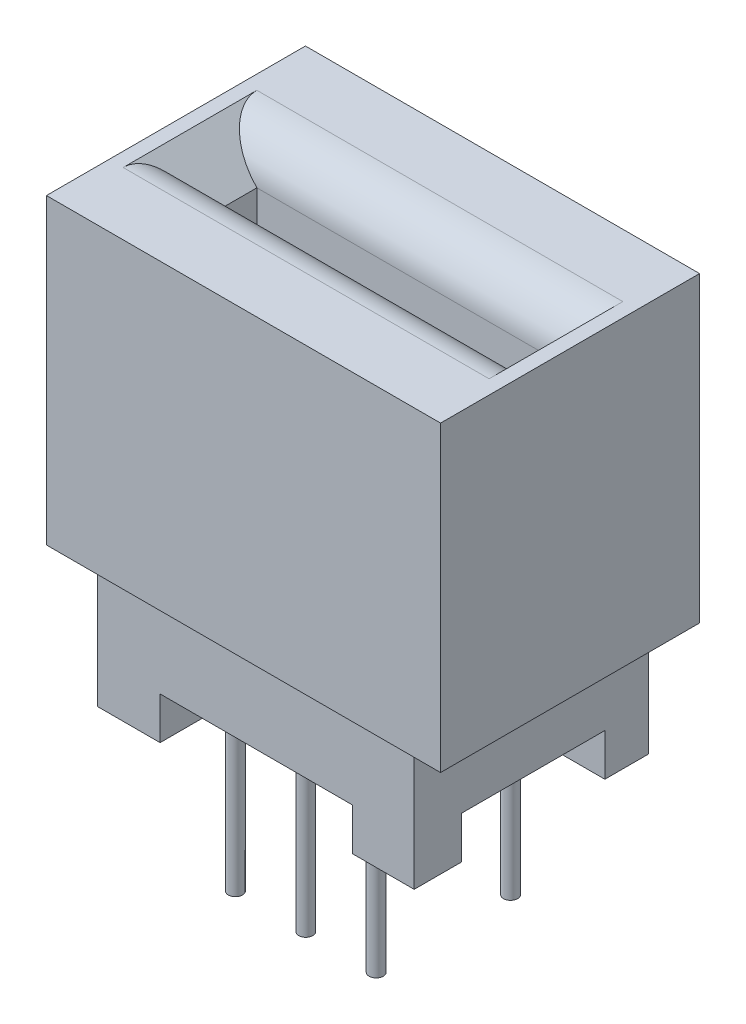
from build123d import *

# Parameters (mm, degrees)
SKETCH1_W            = 14.224
SKETCH1_H            = 9.3472
BOSS_EXTRUDE1_DEPTH  = 10.922
SKETCH2_W            = 11.43
SKETCH2_H            = 8.458212498
BOSS_EXTRUDE2_DEPTH  = 3.048
SKETCH3_W            = 2.25993982
SKETCH3_H            = 1.702901352
SKETCH3_W_2          = 2.231792691
SKETCH3_H_2          = 1.576239268
BOSS_EXTRUDE3_DEPTH  = 1.524
SKETCH4_R            = 0.254
BOSS_EXTRUDE4_DEPTH  = 6.604
LPATTERN1_COUNT      = 3
LPATTERN1_PITCH      = 2.54
LPATTERN1_COUNT_DIR2 = 2
LPATTERN1_PITCH_DIR2 = 4.8514
SKETCH5_W            = 10.16
SKETCH5_H            = 1.778
CUT_EXTRUDE1_DEPTH   = 7.493
CHAMFER1_SIZE        = 1.524
FILLET1_R            = 1.524


with BuildPart() as part:
    # Sketch1 → Boss-Extrude1 (new body)
    with BuildSketch(Plane(origin=(0, 0, 0), x_dir=(1, 0, 0), z_dir=(0, 1, 0))):
        Rectangle(SKETCH1_W, SKETCH1_H)
    extrude(amount=-BOSS_EXTRUDE1_DEPTH)

    # Sketch2 → Boss-Extrude2 (add)
    with BuildSketch(Plane.XZ.offset(10.922)):
        Rectangle(SKETCH2_W, SKETCH2_H)
    extrude(amount=BOSS_EXTRUDE2_DEPTH)

    # Sketch3 → Boss-Extrude3 (add)
    with BuildSketch(Plane.XZ.offset(13.97)):
        with Locations((-4.58503009, 3.377655573)):
            Rectangle(SKETCH3_W, SKETCH3_H)
        with Locations((4.599103655, 3.377655573)):
            Rectangle(SKETCH3_W_2, SKETCH3_H)
        with Locations((4.599103655, -3.440986615)):
            Rectangle(SKETCH3_W_2, SKETCH3_H_2)
        with Locations((-4.58503009, -3.440986615)):
            Rectangle(SKETCH3_W, SKETCH3_H_2)
    extrude(amount=BOSS_EXTRUDE3_DEPTH)

    # Sketch4 → Boss-Extrude4 (add)
    with BuildSketch(Plane.XZ.offset(13.97)):
        with Locations((-2.54, -2.4257)):
            Circle(SKETCH4_R)
    boss_extrude4 = extrude(amount=BOSS_EXTRUDE4_DEPTH)

    # LPattern1: Boss-Extrude4 3 × 2
    with Locations(*[(i * LPATTERN1_PITCH, 0, j * LPATTERN1_PITCH_DIR2) for i in range(LPATTERN1_COUNT) for j in range(LPATTERN1_COUNT_DIR2) if (i, j) != (0, 0)]):
        add(boss_extrude4)

    # Sketch5 → Cut-Extrude1 (cut)
    with BuildSketch(Plane(origin=(0, 0, 0), x_dir=(1, 0, 0), z_dir=(0, 1, 0))):
        Rectangle(SKETCH5_W, SKETCH5_H)
    extrude(amount=-CUT_EXTRUDE1_DEPTH, mode=Mode.SUBTRACT)

    # Chamfer1
    chamfer1_edges = [part.edges().sort_by_distance(p)[0] for p in [
        (-5.08, 0, 0),
        (5.08, 0, 0),
    ]]
    chamfer(chamfer1_edges, length=CHAMFER1_SIZE)

    # Fillet1
    fillet1_edges = [part.edges().sort_by_distance(p)[0] for p in [
        (0, 0, 0.889),
        (0, 0, -0.889),
    ]]
    fillet(fillet1_edges, radius=FILLET1_R)


solid = part.part
